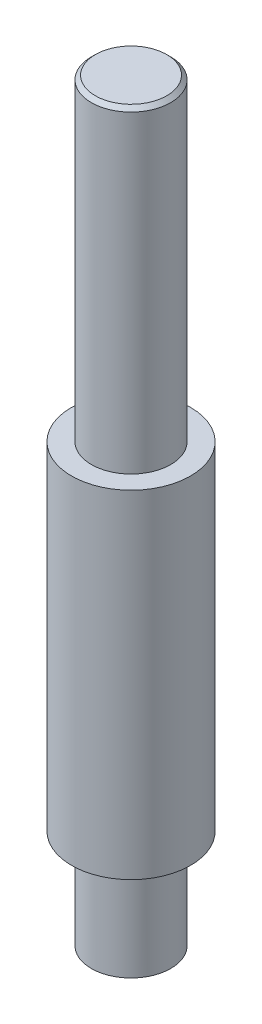
from build123d import *

# Parameters (mm, degrees)
SKETCH1_R           = 10
BOSS_EXTRUDE1_DEPTH = 95
SKETCH3_R           = 14.99
BOSS_EXTRUDE2_DEPTH = 85
CHAMFER1_SIZE       = 1


with BuildPart() as part:
    # Sketch1 → Boss-Extrude1 (new body, symmetric)
    with BuildSketch(Plane(origin=(0, 0, 0), x_dir=(1, 0, 0), z_dir=(0, 1, 0))):
        Circle(SKETCH1_R)
    extrude(amount=BOSS_EXTRUDE1_DEPTH, both=True)

    # Sketch3 → Boss-Extrude2 (add)
    with BuildSketch(Plane(origin=(0, -70, 0), x_dir=(-1, 0, 0), z_dir=(0, -1, 0))):
        Circle(SKETCH3_R)
    extrude(amount=-BOSS_EXTRUDE2_DEPTH)

    # Chamfer1
    chamfer1_edges = [part.edges().sort_by_distance(p)[0] for p in [
        (-10, 95, 0),
    ]]
    chamfer(chamfer1_edges, length=CHAMFER1_SIZE)


solid = part.part
